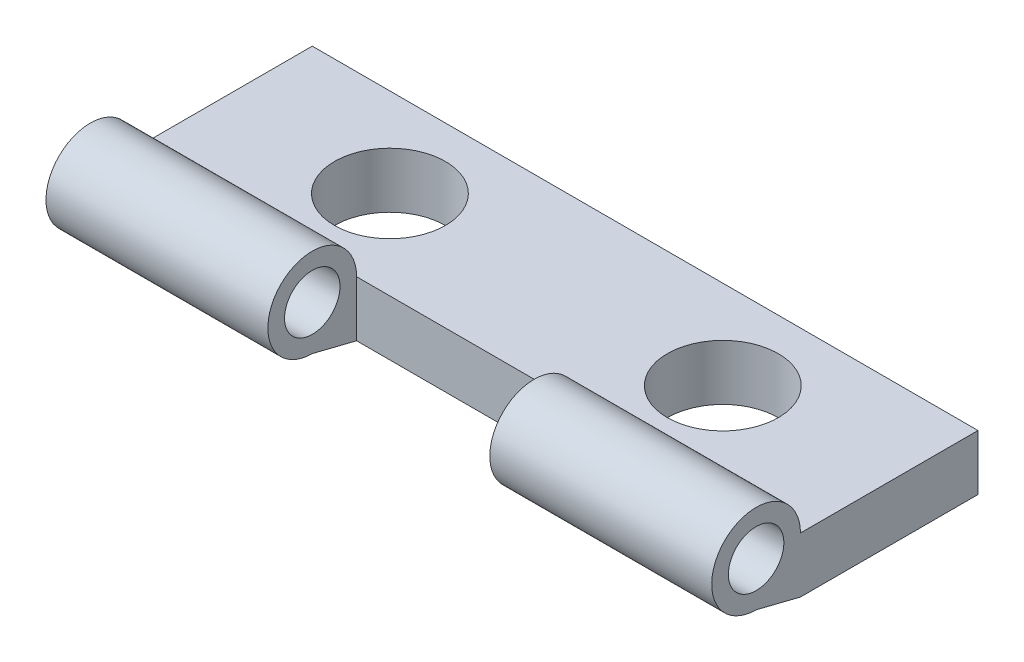
from build123d import *

# Parameters (mm, degrees)
SKETCH1_W                       = 30
SKETCH1_H                       = 8
SKETCH1_R                       = 2.5
BOSS_EXTRUDE1_DEPTH             = 2.5
BOSS_EXTRUDE2_REACH             = 17
SKETCH2_R                       = 1.25
BOSS_EXTRUDE2_DIRECTION_2_REACH = 17
SKETCH4_W                       = 10
SKETCH4_H                       = 4
CUT_EXTRUDE2_DEPTH              = 5.5


with BuildPart() as part:
    # Sketch1 → Boss-Extrude1 (new body)
    with BuildSketch(Plane(origin=(0, 0, 0), x_dir=(1, 0, 0), z_dir=(0, 1, 0))):
        Rectangle(SKETCH1_W, SKETCH1_H)
        with Locations((-7.5, 0)):
            Circle(SKETCH1_R, mode=Mode.SUBTRACT)
        with Locations((7.5, 0)):
            Circle(SKETCH1_R, mode=Mode.SUBTRACT)
    extrude(amount=BOSS_EXTRUDE1_DEPTH)

    # Boss-Extrude2: up to this face of the body (flat: up to its plane)
    boss_extrude2_end = Plane(part.part.faces().sort_by_distance((15, 1.25, 0))[0])
    # Sketch2 → Boss-Extrude2 (add, up to the picked face)
    with BuildSketch(Plane(origin=(0, 0, 0), x_dir=(0, 0, -1), z_dir=(1, 0, 0)), mode=Mode.PRIVATE) as boss_extrude2_sk1:
        with BuildLine():
            Line((-4, 2.5), (-4, 0))
            Line((-4, 0), (-6, 0.5))
            ThreePointArc((-6, 0.5), (-7.414213562, 3.914213562), (-4, 2.5))
        make_face()
        with Locations((-6, 2.5)):
            Circle(SKETCH2_R, mode=Mode.SUBTRACT)
    boss_extrude2_tool1 = split(extrude(boss_extrude2_sk1.sketch, amount=BOSS_EXTRUDE2_REACH, mode=Mode.PRIVATE), bisect_by=boss_extrude2_end, keep=Keep.BOTH, mode=Mode.PRIVATE)
    add(boss_extrude2_tool1.solids().sort_by_distance((0, 1.25, 4.060208))[0])

    # Boss-Extrude2 direction 2: up to this face of the body (flat: up to its plane)
    boss_extrude2_direction_2_end = Plane(part.part.faces().sort_by_distance((-15, 1.25, 0))[0])
    # Sketch2 → Boss-Extrude2 direction 2 (add, up to the picked face)
    with BuildSketch(Plane(origin=(0, 0, 0), x_dir=(0, 0, -1), z_dir=(1, 0, 0)), mode=Mode.PRIVATE) as boss_extrude2_direction_2_sk1:
        with BuildLine():
            Line((-4, 2.5), (-4, 0))
            Line((-4, 0), (-6, 0.5))
            ThreePointArc((-6, 0.5), (-7.414213562, 3.914213562), (-4, 2.5))
        make_face()
        with Locations((-6, 2.5)):
            Circle(SKETCH2_R, mode=Mode.SUBTRACT)
    boss_extrude2_direction_2_tool1 = split(extrude(boss_extrude2_direction_2_sk1.sketch, amount=-BOSS_EXTRUDE2_DIRECTION_2_REACH, mode=Mode.PRIVATE), bisect_by=boss_extrude2_direction_2_end, keep=Keep.BOTH, mode=Mode.PRIVATE)
    add(boss_extrude2_direction_2_tool1.solids().sort_by_distance((0, 1.25, 4.060208))[0])

    # Sketch4 → Cut-Extrude2 (cut, through all)
    with BuildSketch(Plane(origin=(0, 0, 0), x_dir=(1, 0, 0), z_dir=(0, 1, 0))):
        with Locations((0, -6)):
            Rectangle(SKETCH4_W, SKETCH4_H)
    extrude(amount=CUT_EXTRUDE2_DEPTH, mode=Mode.SUBTRACT)


solid = part.part
